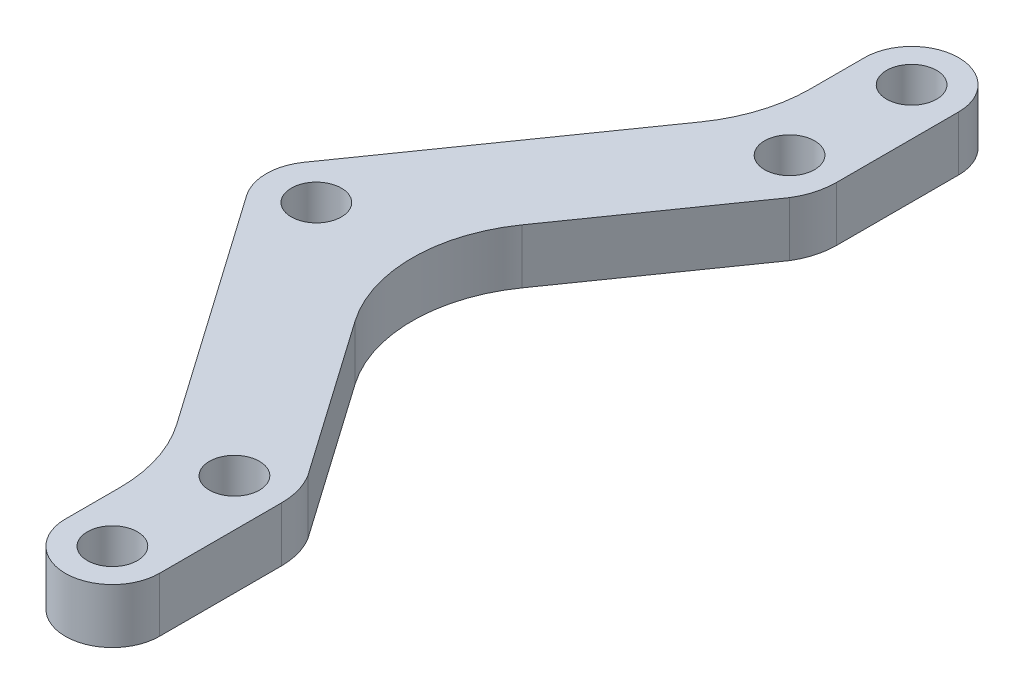
from build123d import *

# Parameters (mm, degrees)
BOSS_EXTRUDE1_DEPTH = 3
SKETCH3_R           = 1.375
CUT_EXTRUDE1_DEPTH  = 4
FILLET1_R           = 8


with BuildPart() as part:
    # Sketch2 → Boss-Extrude1 (new body)
    with BuildSketch(Plane(origin=(0, 0, 0), x_dir=(1, 0, 0), z_dir=(0, 1, 0))):
        with BuildLine():
            Line((-12.66542378, 21.955324516), (-12.66542378, 15.25))
            ThreePointArc((-12.66542378, 15.25), (-12.810144222, 14.202492305), (-13.233463188, 13.233463188))
            Line((-13.233463188, 13.233463188), (-22.5, 0))
            Line((-22.5, 0), (-24.625, 0))
            ThreePointArc((-24.625, 0), (-26, 1.375), (-27.375, 0))
            Line((-27.375, 0), (-28.75, 0))
            ThreePointArc((-28.75, 0), (-28.622713939, 0.826965294), (-28.252638839, 1.57737702))
            Line((-28.252638839, 1.57737702), (-17.83457622, 16.455324516))
            Line((-17.83457622, 16.455324516), (-17.83457622, 21.955324516))
            ThreePointArc((-17.83457622, 21.955324516), (-15.25, 24.539900736), (-12.66542378, 21.955324516))
        make_face()
    boss_extrude1 = extrude(amount=BOSS_EXTRUDE1_DEPTH)

    # Sketch3 → Cut-Extrude1 (cut, through all)
    with BuildSketch(Plane(origin=(0, 3, 0), x_dir=(1, 0, 0), z_dir=(0, 1, 0))):
        with Locations((-15.25, 15.25)):
            Circle(SKETCH3_R)
        with Locations((-15.25, 21.955324516)):
            Circle(SKETCH3_R)
    cut_extrude1 = extrude(amount=-CUT_EXTRUDE1_DEPTH, mode=Mode.SUBTRACT)

    # Mirror2: Boss-Extrude1, Cut-Extrude1 across plane
    add(boss_extrude1.mirror(Plane(origin=(-22.5, 3, 0), x_dir=(1, 0, 0), z_dir=(0, 0, -1))))
    add(cut_extrude1.mirror(Plane(origin=(-22.5, 3, 0), x_dir=(1, 0, 0), z_dir=(0, 0, -1))), mode=Mode.SUBTRACT)

    # Fillet1
    fillet1_edges = [part.edges().sort_by_distance(p)[0] for p in [
        (-17.83457622, 1.5, -16.455324516),
        (-22.5, 1.5, 0),
        (-17.83457622, 1.5, 16.455324516),
    ]]
    fillet(fillet1_edges, radius=FILLET1_R)


solid = part.part
